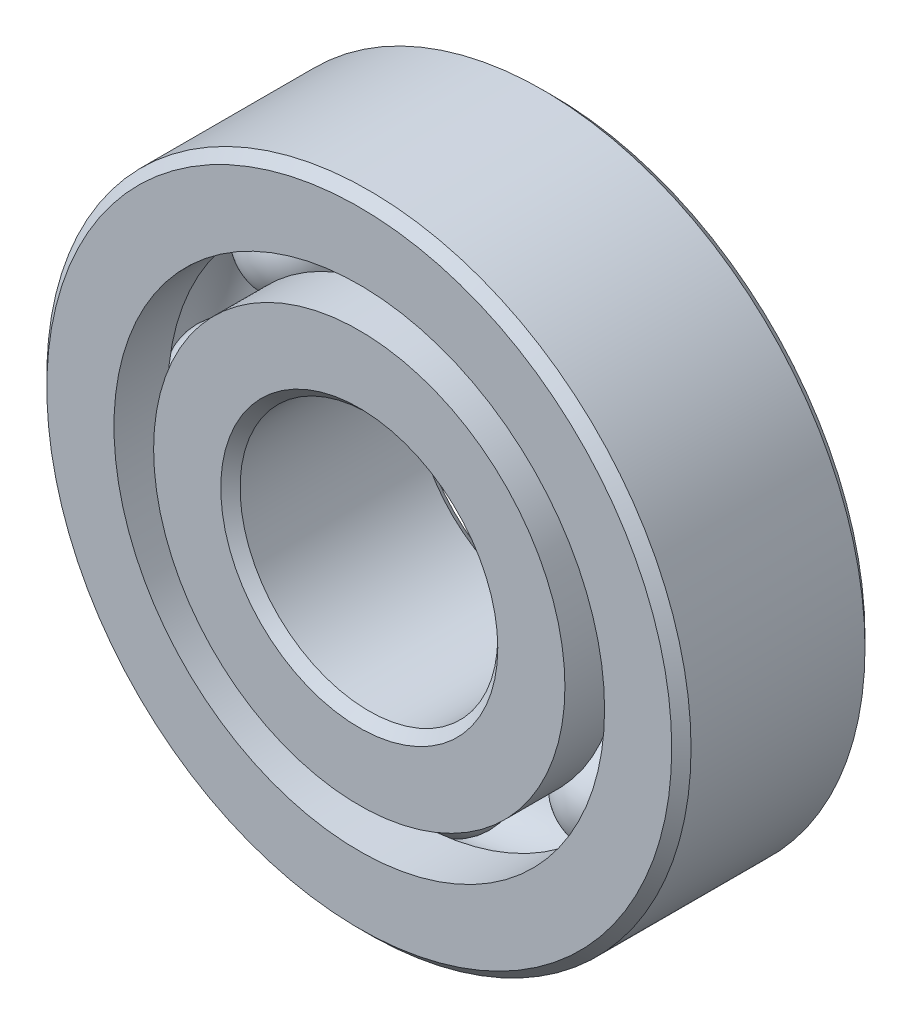
from build123d import *

# Parameters (mm, degrees)
CIRPATTERN1_COUNT = 8


with BuildPart() as part:
    # Sketch1 → Revolve1 (revolve)
    with BuildSketch(Plane(origin=(0, 0, 0), x_dir=(0, 0, -1), z_dir=(1, 0, 0))):
        with BuildLine():
            Line((2.143125, 7.9375), (-2.143125, 7.9375))
            Line((-2.143125, 7.9375), (-2.38125, 7.699375))
            Line((-2.38125, 7.699375), (-2.38125, 6.044711538))
            Line((-2.38125, 6.044711538), (-1.058333333, 6.044711538))
            ThreePointArc((-1.058333333, 6.044711538), (0, 6.721867484), (1.058333333, 6.044711538))
            Line((1.058333333, 6.044711538), (2.38125, 6.044711538))
            Line((2.38125, 6.044711538), (2.38125, 7.699375))
            Line((2.38125, 7.699375), (2.143125, 7.9375))
        make_face()
    revolve(axis=Axis((0, 0, 2.38125), (0, 0, -1)))


with BuildPart() as body_2:
    # Sketch3 → Revolve3 (revolve)
    with BuildSketch(Plane(origin=(0, 0, 0), x_dir=(0, 0, -1), z_dir=(1, 0, 0))):
        with BuildLine():
            Line((-2.38125, 5.067788462), (-1.058333333, 5.067788462))
            ThreePointArc((-1.058333333, 5.067788462), (0, 4.390632516), (1.058333333, 5.067788462))
            Line((1.058333333, 5.067788462), (2.38125, 5.067788462))
            Line((2.38125, 5.067788462), (2.38125, 3.413125))
            Line((2.38125, 3.413125), (2.143125, 3.175))
            Line((2.143125, 3.175), (-2.143125, 3.175))
            Line((-2.143125, 3.175), (-2.38125, 3.413125))
            Line((-2.38125, 3.413125), (-2.38125, 5.067788462))
        make_face()
    revolve(axis=Axis((0, 0, 2.38125), (0, 0, -1)))


with BuildPart() as body_3:
    # Sketch4 → Revolve4 (revolve)
    with BuildSketch(Plane(origin=(0, 0, 0), x_dir=(0, 0, -1), z_dir=(1, 0, 0))):
        with BuildLine():
            Line((-1.165617484, 5.55625), (1.165617484, 5.55625))
            ThreePointArc((1.165617484, 5.55625), (0, 6.721867484), (-1.165617484, 5.55625))
        make_face()
    revolve(axis=Axis((0, 5.55625, 1.165617484), (0, 0, -1)))


with BuildPart() as cirpattern1_1:
    # CirPattern1: pattern copy
    add(body_3.part.rotate(Axis((0, 0, -2.38125), (0, 0, 1)), 1 * 360 / CIRPATTERN1_COUNT))


with BuildPart() as cirpattern1_2:
    # CirPattern1: pattern copy
    add(body_3.part.rotate(Axis((0, 0, -2.38125), (0, 0, 1)), 2 * 360 / CIRPATTERN1_COUNT))


with BuildPart() as cirpattern1_3:
    # CirPattern1: pattern copy
    add(body_3.part.rotate(Axis((0, 0, -2.38125), (0, 0, 1)), 3 * 360 / CIRPATTERN1_COUNT))


with BuildPart() as cirpattern1_4:
    # CirPattern1: pattern copy
    add(body_3.part.rotate(Axis((0, 0, -2.38125), (0, 0, 1)), 4 * 360 / CIRPATTERN1_COUNT))


with BuildPart() as cirpattern1_5:
    # CirPattern1: pattern copy
    add(body_3.part.rotate(Axis((0, 0, -2.38125), (0, 0, 1)), 5 * 360 / CIRPATTERN1_COUNT))


with BuildPart() as cirpattern1_6:
    # CirPattern1: pattern copy
    add(body_3.part.rotate(Axis((0, 0, -2.38125), (0, 0, 1)), 6 * 360 / CIRPATTERN1_COUNT))


with BuildPart() as cirpattern1_7:
    # CirPattern1: pattern copy
    add(body_3.part.rotate(Axis((0, 0, -2.38125), (0, 0, 1)), 7 * 360 / CIRPATTERN1_COUNT))


solid = Compound([part.part, body_2.part, body_3.part, cirpattern1_1.part, cirpattern1_2.part, cirpattern1_3.part, cirpattern1_4.part, cirpattern1_5.part, cirpattern1_6.part, cirpattern1_7.part])
